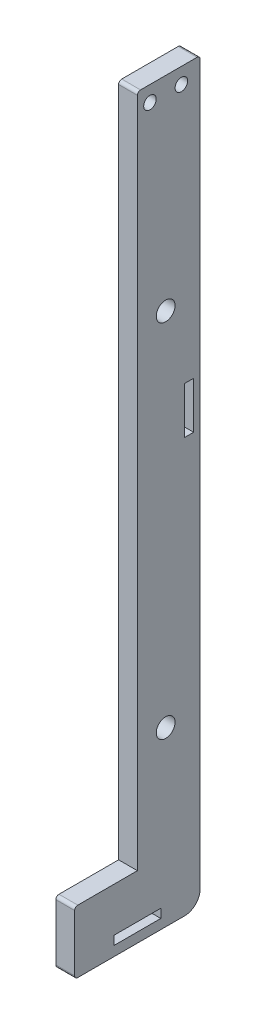
from build123d import *

# Parameters (mm, degrees)
SKETCH_1_R      = 2
SKETCH_1_R_2    = 3
SKETCH_1_W      = 14.9
SKETCH_1_H      = 2.81
SKETCH_1_W_2    = 2.83
SKETCH_1_H_2    = 14.9
EXTRUDE_1_DEPTH = 6
FILLET_1_R      = 1
FILLET_2_R      = 5


with BuildPart() as part:
    # Эскиз1 → Бобышка-Вытянуть1 (new body)
    with BuildSketch(Plane(origin=(0, 0, 0), x_dir=(0, 0, -1), z_dir=(1, 0, 0))):
        Polygon((0, 0), (-20, 0), (-20, -215), (-40, -215), (-40, -235), (0, -235), align=None)
        with Locations((-16, -5)):
            Circle(SKETCH_1_R, mode=Mode.SUBTRACT)
        with Locations((-6, -5)):
            Circle(SKETCH_1_R, mode=Mode.SUBTRACT)
        with Locations((-11, -65)):
            Circle(SKETCH_1_R_2, mode=Mode.SUBTRACT)
        with Locations((-11, -180)):
            Circle(SKETCH_1_R_2, mode=Mode.SUBTRACT)
        with Locations((-20, -230.5)):
            Rectangle(SKETCH_1_W, SKETCH_1_H, mode=Mode.SUBTRACT)
        with Locations((-3.5, -95.5)):
            Rectangle(SKETCH_1_W_2, SKETCH_1_H_2, mode=Mode.SUBTRACT)
    extrude(amount=EXTRUDE_1_DEPTH)

    # Скругление1
    fillet_1_edges = [part.edges().sort_by_distance(p)[0] for p in [
        (3, -235, 40),
        (3, -215, 40),
        (3, 0, 20),
        (3, 0, 0),
    ]]
    fillet(fillet_1_edges, radius=FILLET_1_R)

    # Скругление2
    fillet_2_edges = [part.edges().sort_by_distance(p)[0] for p in [
        (3, -235, 0),
    ]]
    fillet(fillet_2_edges, radius=FILLET_2_R)


solid = part.part
